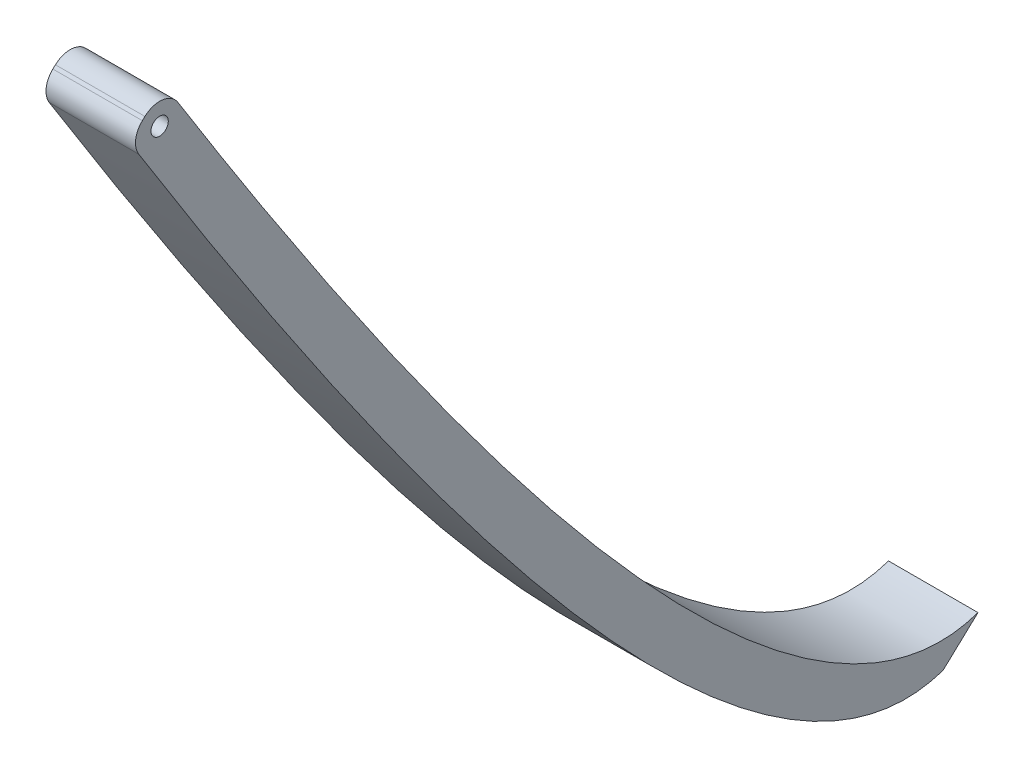
from build123d import *

# Parameters (mm, degrees)
BOSS_EXTRUDE1_DEPTH = 10.52068
FILLET1_R           = 2.54
SKETCH5_R           = 1.016
CUT_EXTRUDE2_DEPTH  = 10.52068


with BuildPart() as part:
    # Sketch3 → Boss-Extrude1 (new body)
    with BuildSketch(Plane(origin=(0, 0, 0), x_dir=(0, 0, -1), z_dir=(1, 0, 0))):
        with BuildLine():
            Line((0, 0), (4.088945173, 3.808709935))
            add(Edge.make_bspline(
                [(4.088945173, 3.808709935), (72.921909903, -107.160022937), (99.782951364, -97.791290065)],
                knots=[0.046886932, 0.046886932, 0.046886932, 0.913353357, 0.913353357, 0.913353357], degree=2))
            Line((99.782951364, -97.791290065), (95.69400619, -101.6))
            add(Edge.make_bspline(
                [(0, 0), (68.832964729, -110.968732872), (95.69400619, -101.6)],
                knots=[0.046886932, 0.046886932, 0.046886932, 0.913353357, 0.913353357, 0.913353357], degree=2))
        make_face()
    extrude(amount=BOSS_EXTRUDE1_DEPTH)

    # Fillet1
    fillet1_edges = [part.edges().sort_by_distance(p)[0] for p in [
        (5.26034, 0, 0),
        (5.26034, 3.808709935, -4.088945173),
    ]]
    fillet(fillet1_edges, radius=FILLET1_R)

    # Sketch5 → Cut-Extrude2 (cut)
    with BuildSketch(Plane.ZY):
        with Locations((-3.562127534, -0.15319586)):
            Circle(SKETCH5_R)
    extrude(amount=-CUT_EXTRUDE2_DEPTH, mode=Mode.SUBTRACT)


solid = part.part
